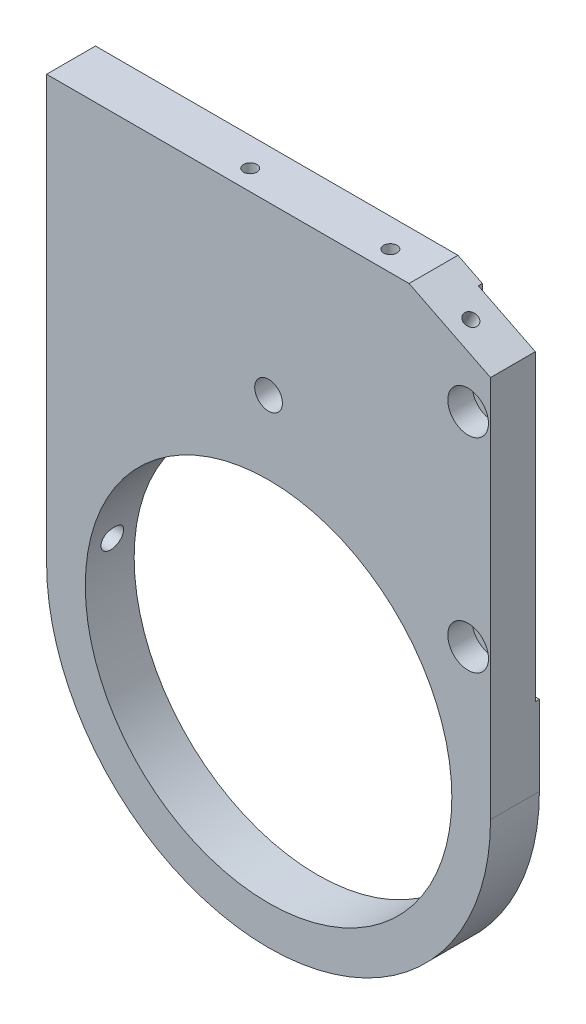
from build123d import *

# Parameters (mm, degrees)
CROQUIS1_R                    = 45
SALIENTE_EXTRUIR1_DEPTH       = 6
TALADRO_ROSCADO_M41_D         = 3.3
TALADRO_ROSCADO_M41_DEPTH     = 20
TALADRO_ROSCADO_M41_TIP       = 0.991420021
TALADRO_ROSCADO_M42_D         = 3.3
TALADRO_ROSCADO_M42_DEPTH     = 20
TALADRO_ROSCADO_M42_TIP       = 0.991420021
CORTAR_EXTRUIR1_DEPTH         = 1
CROQUIS7_R                    = 3.25
CORTAR_EXTRUIR2_DEPTH         = 37.7
CROQUIS8_R                    = 5
CORTAR_EXTRUIR3_DEPTH         = 6
TALADRO_ROSCADO_M6X0_51_D     = 5.5
TALADRO_ROSCADO_M6X0_51_DEPTH = 22.5
TALADRO_ROSCADO_M6X0_51_TIP   = 1.652366702
TALADRO_ROSCADO_M6X0_52_D     = 5.5
TALADRO_ROSCADO_M6X0_52_DEPTH = 10.5
TALADRO_ROSCADO_M6X0_52_TIP   = 1.652366702
TALADRO_ROSCADO_M81_D         = 6.8


with BuildPart() as part:
    # Croquis1 → Saliente-Extruir1 (new body, symmetric)
    with BuildSketch(Plane.XY):
        with BuildLine():
            Line((-54.5, 0), (-54.5, 104))
            Line((-54.5, 104), (34.5, 104))
            Line((34.5, 104), (54.5, 94))
            Line((54.5, 94), (54.5, 0))
            ThreePointArc((54.5, 0), (0, -54.5), (-54.5, 0))
        make_face()
        Circle(CROQUIS1_R, mode=Mode.SUBTRACT)
    extrude(amount=SALIENTE_EXTRUIR1_DEPTH, both=True)

    # Taladro roscado M41
    with Locations(Plane(origin=(48.5, 97, 0), x_dir=(-0.894427191, 0.447213595, 0), z_dir=(0.447213595, 0.894427191, 0))):
        with Locations((4.291796068, -1)):
            Hole(TALADRO_ROSCADO_M41_D / 2, depth=TALADRO_ROSCADO_M41_DEPTH)
            with Locations((0, 0, -(TALADRO_ROSCADO_M41_DEPTH + TALADRO_ROSCADO_M41_TIP / 2))):  # 118° drill point
                Cone(0, TALADRO_ROSCADO_M41_D / 2, TALADRO_ROSCADO_M41_TIP, mode=Mode.SUBTRACT)

    # Taladro roscado M42
    with Locations(Plane(origin=(0, 104, 0), x_dir=(-1, 0, 0), z_dir=(0, 1, 0))):
        with Locations((9.5, -1), (-24.9, -1)):
            Hole(TALADRO_ROSCADO_M42_D / 2, depth=TALADRO_ROSCADO_M42_DEPTH)
            with Locations((0, 0, -(TALADRO_ROSCADO_M42_DEPTH + TALADRO_ROSCADO_M42_TIP / 2))):  # 118° drill point
                Cone(0, TALADRO_ROSCADO_M42_D / 2, TALADRO_ROSCADO_M42_TIP, mode=Mode.SUBTRACT)

    # Croquis6 → Cortar-Extruir1 (cut)
    with BuildSketch(Plane.XY.offset(6)):
        with BuildLine():
            Line((40.5, 104), (65.659367038, 104))
            Line((65.659367038, 104), (65.659367038, 19.6))
            Line((65.659367038, 19.6), (45.5, 19.6))
            ThreePointArc((45.5, 19.6), (41.964466094, 21.064466094), (40.5, 24.6))
            Line((40.5, 24.6), (40.5, 104))
        make_face()
    extrude(amount=-CORTAR_EXTRUIR1_DEPTH, mode=Mode.SUBTRACT)

    # Croquis7 → Cortar-Extruir2 (cut)
    with BuildSketch(Plane.XY.offset(5)):
        with Locations((49, 84)):
            Circle(CROQUIS7_R)
        with Locations((49, 34)):
            Circle(CROQUIS7_R)
    extrude(amount=-CORTAR_EXTRUIR2_DEPTH, mode=Mode.SUBTRACT)

    # Croquis8 → Cortar-Extruir3 (cut)
    with BuildSketch(Plane(origin=(0, 0, -6), x_dir=(-1, 0, 0), z_dir=(0, 0, -1))):
        with Locations((-49, 84)):
            Circle(CROQUIS8_R)
        with Locations((-49, 34)):
            Circle(CROQUIS8_R)
    extrude(amount=-CORTAR_EXTRUIR3_DEPTH, mode=Mode.SUBTRACT)

    # Taladro roscado M6x0.51
    with Locations(Plane.ZY.offset(54.5)):
        with Locations((0, 96.5), (0, 51.7)):
            Hole(TALADRO_ROSCADO_M6X0_51_D / 2, depth=TALADRO_ROSCADO_M6X0_51_DEPTH)
            with Locations((0, 0, -(TALADRO_ROSCADO_M6X0_51_DEPTH + TALADRO_ROSCADO_M6X0_51_TIP / 2))):  # 118° drill point
                Cone(0, TALADRO_ROSCADO_M6X0_51_D / 2, TALADRO_ROSCADO_M6X0_51_TIP, mode=Mode.SUBTRACT)

    # Taladro roscado M6x0.52
    with Locations(Plane.ZY.offset(54.5)):
        with Locations((0, 7.5)):
            Hole(TALADRO_ROSCADO_M6X0_52_D / 2, depth=TALADRO_ROSCADO_M6X0_52_DEPTH)
            with Locations((0, 0, -(TALADRO_ROSCADO_M6X0_52_DEPTH + TALADRO_ROSCADO_M6X0_52_TIP / 2))):  # 118° drill point
                Cone(0, TALADRO_ROSCADO_M6X0_52_D / 2, TALADRO_ROSCADO_M6X0_52_TIP, mode=Mode.SUBTRACT)

    # Taladro roscado M81 (through all)
    with Locations(Plane.XY.offset(6)):
        with Locations((0, 63)):
            Hole(TALADRO_ROSCADO_M81_D / 2)


with BuildPart() as body_2:
    # Simetría1: mirrored copy
    add(part.part.mirror(Plane.XY.offset(-6)))


solid = body_2.part
